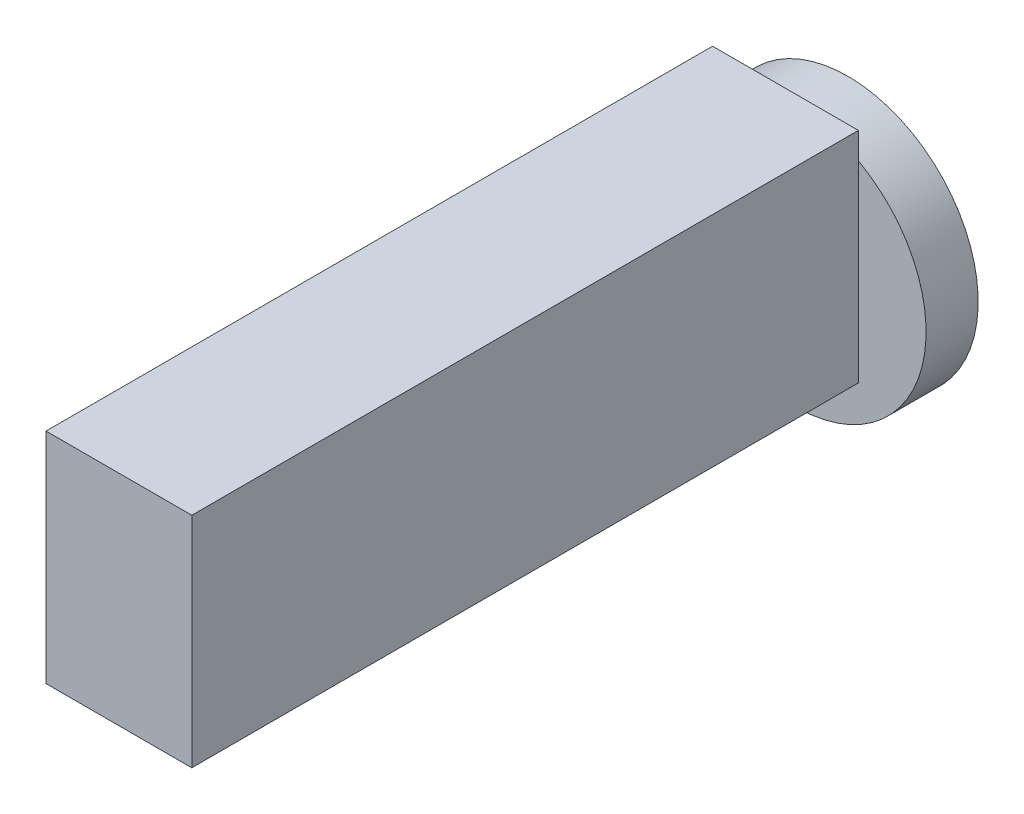
from build123d import *

# Parameters (mm, degrees)
SKETCH1_R           = 5
BODY_DEPTH          = 100
SKETCH2_R           = 25
HEAD_DEPTH          = 10
SWEEP1_PITCH        = 28.5
SWEEP1_HEIGHT       = 105
SWEEP1_RADIUS       = 7.5
SKETCH18_R          = 14.102018713
CUT_EXTRUDE1_DEPTH  = 17
SKETCH19_W          = 28
SKETCH19_H          = 42
SKETCH19_W_2        = 24
SKETCH19_H_2        = 38
FRAME_DEPTH         = 128
SKETCH19_2_W        = 24
SKETCH19_2_H        = 38
BOSS_EXTRUDE3_DEPTH = 2
SKETCH23_W          = 24
SKETCH23_H          = 28
HOLE_DEPTH          = 2
SKETCH23_3_W        = 24
SKETCH23_3_H        = 28
CUT_EXTRUDE2_DEPTH  = 2


with BuildPart() as part:
    # Sketch1 → Body (new body)
    with BuildSketch(Plane.XY):
        Circle(SKETCH1_R)
    extrude(amount=-BODY_DEPTH)

    # Sketch2 → Head (add)
    with BuildSketch(Plane(origin=(0, 0, -100), x_dir=(-1, 0, 0), z_dir=(0, 0, -1))):
        Circle(SKETCH2_R)
    extrude(amount=HEAD_DEPTH)

    # Sweep1: sweep along a helix
    with BuildLine() as sweep1_path:
        Helix(SWEEP1_PITCH, SWEEP1_HEIGHT, SWEEP1_RADIUS, center=(0, 0, 0), direction=(0, 0, -1))
    # Sketch17 → Sweep1 (sweep)
    with BuildSketch(Plane(origin=(-7.5, 0, 0), x_dir=(1, 0, 0), z_dir=(-5.979636411115962e-15, 0.8556798386028079, -0.5175055688673048))):
        Polygon((-2.916813088, -0.138186574), (3.083186912, -3.602288189), (3.083186912, 3.325915041), align=None)
    sweep(path=sweep1_path.line, is_frenet=True)

    # Sketch18 → Cut-Extrude1 (cut)
    with BuildSketch(Plane.XY):
        Circle(SKETCH18_R)
    extrude(amount=CUT_EXTRUDE1_DEPTH, mode=Mode.SUBTRACT)


with BuildPart() as body_2:
    # Sketch19 → Frame (new body)
    with BuildSketch(Plane.XY.offset(30)):
        with Locations((0, 8)):
            Rectangle(SKETCH19_W, SKETCH19_H)
        with Locations((0, 8)):
            Rectangle(SKETCH19_W_2, SKETCH19_H_2, mode=Mode.SUBTRACT)
    extrude(amount=-FRAME_DEPTH)

    # Sketch19_2 → Boss-Extrude3 (add)
    with BuildSketch(Plane.XY.offset(30)):
        with Locations((0, 8)):
            Rectangle(SKETCH19_2_W, SKETCH19_2_H)
    extrude(amount=-BOSS_EXTRUDE3_DEPTH)

    # Sketch23 → Hole (add)
    with BuildSketch(Plane(origin=(0, -11, 0), x_dir=(1, 0, 0), z_dir=(0, 1, 0))):
        with Locations((0, -14)):
            Rectangle(SKETCH23_W, SKETCH23_H)
    extrude(amount=-HOLE_DEPTH)

    # Sketch23_3 → Cut-Extrude2 (cut)
    with BuildSketch(Plane(origin=(0, -11, 0), x_dir=(1, 0, 0), z_dir=(0, 1, 0))):
        with Locations((0, -14)):
            Rectangle(SKETCH23_3_W, SKETCH23_3_H)
    extrude(amount=-CUT_EXTRUDE2_DEPTH, mode=Mode.SUBTRACT)


solid = Compound([part.part, body_2.part])
